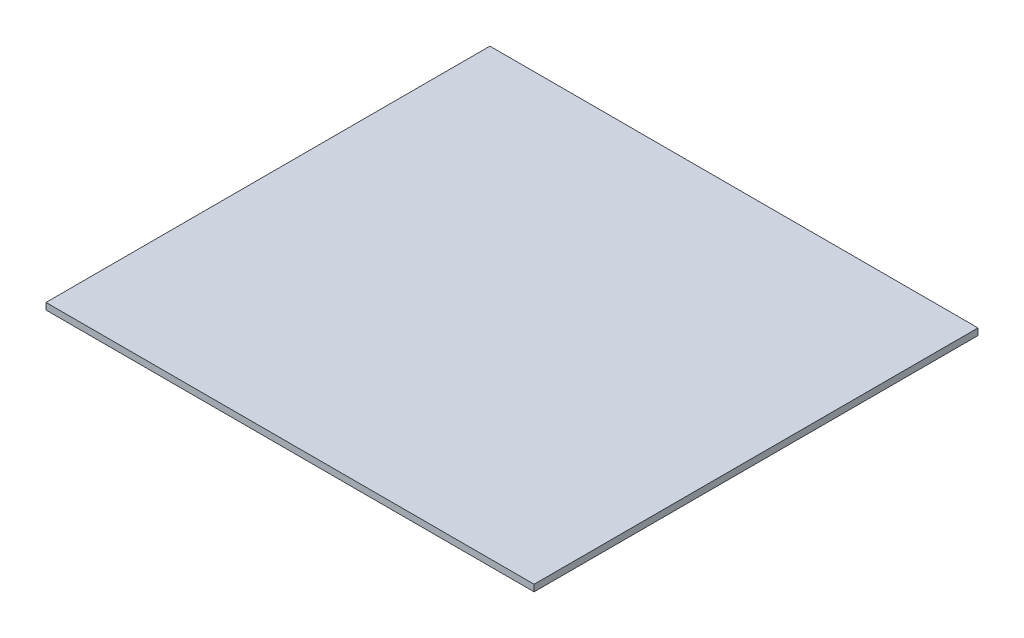
from build123d import *

# Parameters (mm, degrees)
SKETCH1_W           = 221
SKETCH1_H           = 201
BOSS_EXTRUDE1_DEPTH = 3


with BuildPart() as part:
    # Sketch1 → Boss-Extrude1 (new body)
    with BuildSketch(Plane(origin=(0, 0, 0), x_dir=(1, 0, 0), z_dir=(0, 1, 0))):
        Rectangle(SKETCH1_W, SKETCH1_H)
    extrude(amount=BOSS_EXTRUDE1_DEPTH)


solid = part.part
